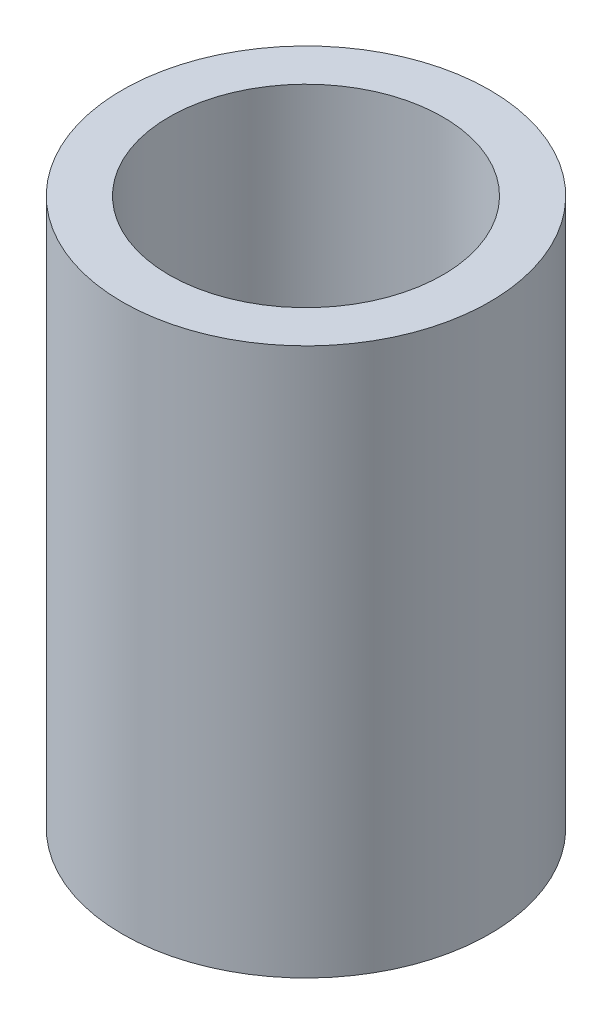
from build123d import *

# Parameters (mm, degrees)
SKETCH1_W = 13.0302
SKETCH1_H = 152.4


with BuildPart() as part:
    # Sketch1 → Revolve1 (revolve)
    with BuildSketch(Plane.XY):
        with Locations((-44.6151, -76.2)):
            Rectangle(SKETCH1_W, SKETCH1_H)
    revolve(axis=Axis((0, 0, 0), (0, -1, 0)))


solid = part.part
